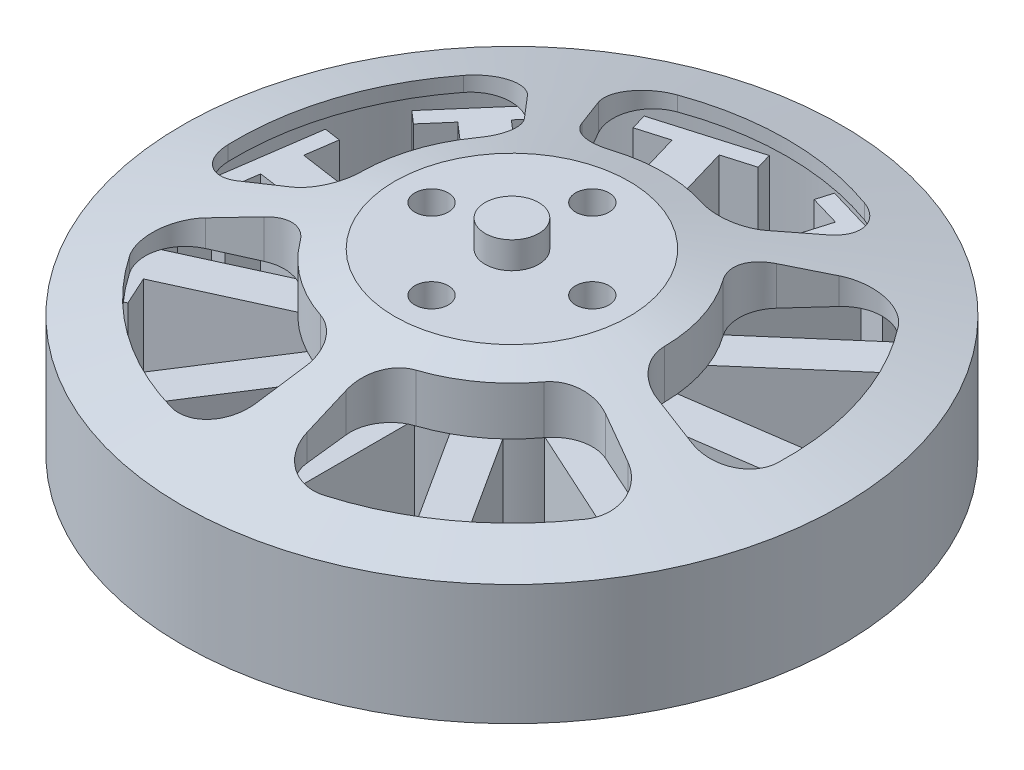
from build123d import *

# Parameters (mm, degrees)
CROQUIS1_R              = 24.6
SALIENTE_EXTRUIR1_DEPTH = 9
CROQUIS4_R              = 22.838904737
CORTAR_EXTRUIR1_DEPTH   = 9
CORTAR_EXTRUIR2_DEPTH   = 14.3
SALIENTE_EXTRUIR2_START = -6
CROQUIS3_R              = 2
SALIENTE_EXTRUIR2_DEPTH = 8
SALIENTE_EXTRUIR3_DEPTH = 8
CROQUIS7_R              = 7.5
SALIENTE_EXTRUIR4_DEPTH = 5
CROQUIS8_R              = 12.25
SALIENTE_EXTRUIR5_DEPTH = 1.2
CROQUIS9_R              = 2
SALIENTE_EXTRUIR6_DEPTH = 1.8
SALIENTE_EXTRUIR7_DEPTH = 0.8
CROQUIS11_R             = 1.25
CORTAR_EXTRUIR3_DEPTH   = 3
CROQUIS12_R             = 1.348388042
CORTAR_EXTRUIR4_DEPTH   = 6
SALIENTE_EXTRUIR8_START = 1
SALIENTE_EXTRUIR8_DEPTH = 2


with BuildPart() as part:
    # Croquis1 → Saliente-Extruir1 (new body)
    with BuildSketch(Plane(origin=(0, 0, 0), x_dir=(1, 0, 0), z_dir=(0, 1, 0))):
        Circle(CROQUIS1_R)
    extrude(amount=SALIENTE_EXTRUIR1_DEPTH)

    # Croquis2 → Revolución1 (revolve)
    with BuildSketch(Plane.XY):
        Polygon((-24.6, 9), (-8.75, 13.3), (0, 13.3), (0, 9), align=None)
    revolve(axis=Axis((0, 13.3, 0), (0, -1, 0)))

    # Croquis4 → Cortar-Extruir1 (cut)
    with BuildSketch(Plane.XZ):
        Circle(CROQUIS4_R)
    extrude(amount=-CORTAR_EXTRUIR1_DEPTH, mode=Mode.SUBTRACT)

    # Croquis5 → Cortar-Extruir2 (cut, through all)
    with BuildSketch(Plane(origin=(0, 13.3, 0), x_dir=(1, 0, 0), z_dir=(0, 1, 0))):
        with BuildLine():
            Line((-8.570425655, 15.0190469), (-6.930143541, 12.144571933))
            ThreePointArc((-6.930143541, 12.144571933), (-5.416422682, 10.837196574), (-3.417344005, 10.7718849))
            ThreePointArc((-3.417344005, 10.7718849), (0, 11.300962098), (3.417344005, 10.7718849))
            ThreePointArc((3.417344005, 10.7718849), (5.416422682, 10.837196574), (6.930143541, 12.144571933))
            Line((6.930143541, 12.144571933), (8.570425655, 15.0190469))
            ThreePointArc((8.570425655, 15.0190469), (8.780099609, 17.542313757), (6.984398181, 19.327333417))
            ThreePointArc((6.984398181, 19.327333417), (0, 20.550611547), (-6.984398181, 19.327333417))
            ThreePointArc((-6.984398181, 19.327333417), (-8.780099609, 17.542313757), (-8.570425655, 15.0190469))
        make_face()
        with BuildLine():
            Line((11.635555246, 12.792099897), (9.408642147, 10.34383729))
            ThreePointArc((9.408642147, 10.34383729), (8.633019762, 8.500201999), (9.188653954, 6.57878278))
            ThreePointArc((9.188653954, 6.57878278), (10.747853644, 3.492189341), (11.3006887, 0.078608211))
            ThreePointArc((11.3006887, 0.078608211), (11.980553077, -1.802446174), (13.691706402, -2.838079057))
            Line((13.691706402, -2.838079057), (16.932369599, -3.509818435))
            ThreePointArc((16.932369599, -3.509818435), (19.396931801, -2.929497875), (20.539684122, -0.670082921))
            ThreePointArc((20.539684122, -0.670082921), (19.544793026, 6.350488213), (16.223088655, 12.615031884))
            ThreePointArc((16.223088655, 12.615031884), (13.970531818, 13.771244019), (11.635555246, 12.792099897))
        make_face()
        with BuildLine():
            Line((15.761594275, -7.113094375), (12.745004176, -5.751728914))
            ThreePointArc((12.745004176, -5.751728914), (10.751922321, -5.583782827), (9.096244459, -6.705973537))
            ThreePointArc((9.096244459, -6.705973537), (6.642538858, -9.14267039), (3.566865708, -10.723302354))
            ThreePointArc((3.566865708, -10.723302354), (1.987966324, -11.951169572), (1.53179638, -13.898601253))
            Line((1.53179638, -13.898601253), (1.894354267, -17.188233987))
            ThreePointArc((1.894354267, -17.188233987), (3.207863522, -19.352843014), (5.709824725, -19.741467437))
            ThreePointArc((5.709824725, -19.741467437), (12.079346393, -16.625793986), (17.010818372, -11.530814943))
            ThreePointArc((17.010818372, -11.530814943), (17.414363114, -9.031216887), (15.761594275, -7.113094375))
        make_face()
        with BuildLine():
            Line((-1.894354267, -17.188233987), (-1.53179638, -13.898601253))
            ThreePointArc((-1.53179638, -13.898601253), (-1.987966324, -11.951169572), (-3.566865708, -10.723302354))
            ThreePointArc((-3.566865708, -10.723302354), (-6.642538858, -9.14267039), (-9.096244459, -6.705973537))
            ThreePointArc((-9.096244459, -6.705973537), (-10.751922321, -5.583782827), (-12.745004176, -5.751728914))
            Line((-12.745004176, -5.751728914), (-15.761594275, -7.113094375))
            ThreePointArc((-15.761594275, -7.113094375), (-17.414363114, -9.031216887), (-17.010818372, -11.530814943))
            ThreePointArc((-17.010818372, -11.530814943), (-12.079346393, -16.625793986), (-5.709824725, -19.741467437))
            ThreePointArc((-5.709824725, -19.741467437), (-3.207863522, -19.352843014), (-1.894354267, -17.188233987))
        make_face()
        with BuildLine():
            Line((-16.932369599, -3.509818435), (-13.691706402, -2.838079057))
            ThreePointArc((-13.691706402, -2.838079057), (-11.980553077, -1.802446174), (-11.3006887, 0.078608211))
            ThreePointArc((-11.3006887, 0.078608211), (-10.747853644, 3.492189341), (-9.188653954, 6.57878278))
            ThreePointArc((-9.188653954, 6.57878278), (-8.633019762, 8.500201999), (-9.408642147, 10.34383729))
            Line((-9.408642147, 10.34383729), (-11.635555246, 12.792099897))
            ThreePointArc((-11.635555246, 12.792099897), (-13.970531818, 13.771244019), (-16.223088655, 12.615031884))
            ThreePointArc((-16.223088655, 12.615031884), (-19.544793026, 6.350488213), (-20.539684122, -0.670082921))
            ThreePointArc((-20.539684122, -0.670082921), (-19.396931801, -2.929497875), (-16.932369599, -3.509818435))
        make_face()
    extrude(amount=-CORTAR_EXTRUIR2_DEPTH, mode=Mode.SUBTRACT)

    # Croquis3 → Saliente-Extruir2 (add)
    with BuildSketch(Plane(origin=(0, 13.3, 0), x_dir=(1, 0, 0), z_dir=(0, 1, 0)).offset(SALIENTE_EXTRUIR2_START)):
        Circle(CROQUIS3_R)
    extrude(amount=SALIENTE_EXTRUIR2_DEPTH)

    # Croquis6 → Saliente-Extruir3 (add)
    with BuildSketch(Plane.XZ.offset(-7.3)):
        with BuildLine():
            Line((-1.41776314, 20.230911324), (-1.41776314, 8.691927398))
            ThreePointArc((-1.41776314, 8.691927398), (-2.48116113, 8.450058797), (-3.506512483, 8.078615254))
            Line((-3.506512483, 8.078615254), (-9.744958186, 17.785826247))
            Line((-9.744958186, 17.785826247), (-7.771261406, 19.054244148))
            Line((-7.771261406, 19.054244148), (-8.431305766, 20.08129322))
            Line((-8.431305766, 20.08129322), (-14.764095827, 16.011456172))
            Line((-14.764095827, 16.011456172), (-14.104051466, 14.984407099))
            Line((-14.104051466, 14.984407099), (-12.130354686, 16.252825001))
            Line((-12.130354686, 16.252825001), (-5.891908984, 6.545614008))
            ThreePointArc((-5.891908984, 6.545614008), (-6.655732261, 5.767224834), (-7.317495169, 4.900399847))
            Line((-7.317495169, 4.900399847), (-17.813724142, 9.693867005))
            Line((-17.813724142, 9.693867005), (-16.839103244, 11.827989086))
            Line((-16.839103244, 11.827989086), (-17.949632544, 12.335150824))
            Line((-17.949632544, 12.335150824), (-21.076794527, 5.487621234))
            Line((-21.076794527, 5.487621234), (-19.966265227, 4.980459496))
            Line((-19.966265227, 4.980459496), (-18.991644329, 7.114581576))
            Line((-18.991644329, 7.114581576), (-8.495415356, 2.321114419))
            ThreePointArc((-8.495415356, 2.321114419), (-8.717155427, 1.253337736), (-8.805224842, 0.166342114))
            Line((-8.805224842, 0.166342114), (-20.226758549, -1.475826517))
            Line((-20.226758549, -1.475826517), (-20.560648782, 0.846431062))
            Line((-20.560648782, 0.846431062), (-21.769077816, 0.672685197))
            Line((-21.769077816, 0.672685197), (-20.697759886, -6.778494673))
            Line((-20.697759886, -6.778494673), (-19.489330852, -6.604748808))
            Line((-19.489330852, -6.604748808), (-19.823221085, -4.282491229))
            Line((-19.823221085, -4.282491229), (-8.401687378, -2.640322598))
            ThreePointArc((-8.401687378, -2.640322598), (-8.010943337, -3.658475238), (-7.497357842, -4.620528066))
            Line((-7.497357842, -4.620528066), (-16.217940032, -12.176955548))
            Line((-16.217940032, -12.176955548), (-17.754333606, -10.403862844))
            Line((-17.754333606, -10.403862844), (-18.676994694, -11.203353227))
            Line((-18.676994694, -11.203353227), (-13.747332725, -16.892486415))
            Line((-13.747332725, -16.892486415), (-12.824671637, -16.092996032))
            Line((-12.824671637, -16.092996032), (-14.361065211, -14.319903328))
            Line((-14.361065211, -14.319903328), (-5.640483021, -6.763475845))
            ThreePointArc((-5.640483021, -6.763475845), (-4.761313341, -7.408748173), (-3.809132701, -7.940413231))
            Line((-3.809132701, -7.940413231), (-7.060040146, -19.011987231))
            Line((-7.060040146, -19.011987231), (-9.311142957, -18.351003807))
            Line((-9.311142957, -18.351003807), (-9.655097722, -19.522406161))
            Line((-9.655097722, -19.522406161), (-2.432224557, -21.643233077))
            Line((-2.432224557, -21.643233077), (-2.088269792, -20.471830723))
            Line((-2.088269792, -20.471830723), (-4.339372603, -19.8108473))
            Line((-4.339372603, -19.8108473), (-1.088465159, -8.7392733))
            ThreePointArc((-1.088465159, -8.7392733), (0, -8.806795911), (1.088465159, -8.7392733))
            Line((1.088465159, -8.7392733), (4.339372603, -19.8108473))
            Line((4.339372603, -19.8108473), (2.088269792, -20.471830723))
            Line((2.088269792, -20.471830723), (2.432224557, -21.643233077))
            Line((2.432224557, -21.643233077), (9.655097722, -19.522406161))
            Line((9.655097722, -19.522406161), (9.311142957, -18.351003807))
            Line((9.311142957, -18.351003807), (7.060040146, -19.011987231))
            Line((7.060040146, -19.011987231), (3.809132701, -7.940413231))
            ThreePointArc((3.809132701, -7.940413231), (4.761313341, -7.408748173), (5.640483021, -6.763475845))
            Line((5.640483021, -6.763475845), (14.361065211, -14.319903328))
            Line((14.361065211, -14.319903328), (12.824671637, -16.092996032))
            Line((12.824671637, -16.092996032), (13.747332725, -16.892486415))
            Line((13.747332725, -16.892486415), (18.676994694, -11.203353227))
            Line((18.676994694, -11.203353227), (17.754333606, -10.403862844))
            Line((17.754333606, -10.403862844), (16.217940032, -12.176955548))
            Line((16.217940032, -12.176955548), (7.497357842, -4.620528066))
            ThreePointArc((7.497357842, -4.620528066), (8.010943337, -3.658475238), (8.401687378, -2.640322598))
            Line((8.401687378, -2.640322598), (19.823221085, -4.282491229))
            Line((19.823221085, -4.282491229), (19.489330852, -6.604748808))
            Line((19.489330852, -6.604748808), (20.697759886, -6.778494673))
            Line((20.697759886, -6.778494673), (21.769077816, 0.672685197))
            Line((21.769077816, 0.672685197), (20.560648782, 0.846431062))
            Line((20.560648782, 0.846431062), (20.226758549, -1.475826517))
            Line((20.226758549, -1.475826517), (8.805224842, 0.166342114))
            ThreePointArc((8.805224842, 0.166342114), (8.717155427, 1.253337736), (8.495415356, 2.321114419))
            Line((8.495415356, 2.321114419), (18.991644329, 7.114581576))
            Line((18.991644329, 7.114581576), (19.966265227, 4.980459496))
            Line((19.966265227, 4.980459496), (21.076794527, 5.487621234))
            Line((21.076794527, 5.487621234), (17.949632544, 12.335150824))
            Line((17.949632544, 12.335150824), (16.839103244, 11.827989086))
            Line((16.839103244, 11.827989086), (17.813724142, 9.693867005))
            Line((17.813724142, 9.693867005), (7.317495169, 4.900399847))
            ThreePointArc((7.317495169, 4.900399847), (6.655732261, 5.767224834), (5.891908984, 6.545614008))
            Line((5.891908984, 6.545614008), (12.130354686, 16.252825001))
            Line((12.130354686, 16.252825001), (14.104051466, 14.984407099))
            Line((14.104051466, 14.984407099), (14.764095827, 16.011456172))
            Line((14.764095827, 16.011456172), (8.431305766, 20.08129322))
            Line((8.431305766, 20.08129322), (7.771261406, 19.054244148))
            Line((7.771261406, 19.054244148), (9.744958186, 17.785826247))
            Line((9.744958186, 17.785826247), (3.506512483, 8.078615254))
            ThreePointArc((3.506512483, 8.078615254), (2.48116113, 8.450058797), (1.41776314, 8.691927398))
            Line((1.41776314, 8.691927398), (1.41776314, 20.230911324))
            Line((1.41776314, 20.230911324), (3.76390102, 20.230911324))
            Line((3.76390102, 20.230911324), (3.76390102, 21.451766907))
            Line((3.76390102, 21.451766907), (-3.76390102, 21.451766907))
            Line((-3.76390102, 21.451766907), (-3.76390102, 20.230911324))
            Line((-3.76390102, 20.230911324), (-1.41776314, 20.230911324))
        make_face()
    extrude(amount=SALIENTE_EXTRUIR3_DEPTH)

    # Croquis7 → Saliente-Extruir4 (add)
    with BuildSketch(Plane.XZ.offset(0.7)):
        Circle(CROQUIS7_R)
    extrude(amount=SALIENTE_EXTRUIR4_DEPTH)

    # Croquis8 → Saliente-Extruir5 (add)
    with BuildSketch(Plane.XZ.offset(5.7)):
        Circle(CROQUIS8_R)
    extrude(amount=SALIENTE_EXTRUIR5_DEPTH)

    # Croquis9 → Saliente-Extruir6 (add)
    with BuildSketch(Plane.XZ.offset(6.9)):
        Circle(CROQUIS9_R)
    extrude(amount=SALIENTE_EXTRUIR6_DEPTH)

    # Croquis10 → Saliente-Extruir7 (add)
    with BuildSketch(Plane.XZ.offset(6.9)):
        with BuildLine():
            Line((-1.85, 4.270295341), (-1.85, 1.681517172))
            ThreePointArc((-1.85, 1.681517172), (0, -2.5), (1.85, 1.681517172))
            Line((1.85, 1.681517172), (1.85, 4.270295341))
            Line((1.85, 4.270295341), (-1.85, 4.270295341))
        make_face()
    extrude(amount=SALIENTE_EXTRUIR7_DEPTH)

    # Croquis11 → Cortar-Extruir3 (cut)
    with BuildSketch(Plane(origin=(0, 13.3, 0), x_dir=(1, 0, 0), z_dir=(0, 1, 0))):
        with Locations((0, -6)):
            Circle(CROQUIS11_R)
        with Locations((6, 0)):
            Circle(CROQUIS11_R)
        with Locations((0, 6)):
            Circle(CROQUIS11_R)
        with Locations((-6, 0)):
            Circle(CROQUIS11_R)
    extrude(amount=-CORTAR_EXTRUIR3_DEPTH, mode=Mode.SUBTRACT)

    # Croquis12 → Cortar-Extruir4 (cut)
    with BuildSketch(Plane.XZ.offset(6.9)):
        with Locations((0, 8)):
            Circle(CROQUIS12_R)
        with Locations((0, -8)):
            Circle(CROQUIS12_R)
        with Locations((-9.5, 0)):
            Circle(CROQUIS12_R)
        with Locations((9.5, 0)):
            Circle(CROQUIS12_R)
    extrude(amount=-CORTAR_EXTRUIR4_DEPTH, mode=Mode.SUBTRACT)

    # Croquis13 → Saliente-Extruir8 (add)
    with BuildSketch(Plane(origin=(0, -5.7, 0), x_dir=(1, 0, 0), z_dir=(0, 1, 0)).offset(SALIENTE_EXTRUIR8_START)):
        Polygon((-6.908867887, 2.747843539), (-3.184587628, 6.472123798), (-16.034776003, 19.322312173), (-19.759056262, 15.598031914), align=None)
    extrude(amount=SALIENTE_EXTRUIR8_DEPTH)


solid = part.part
